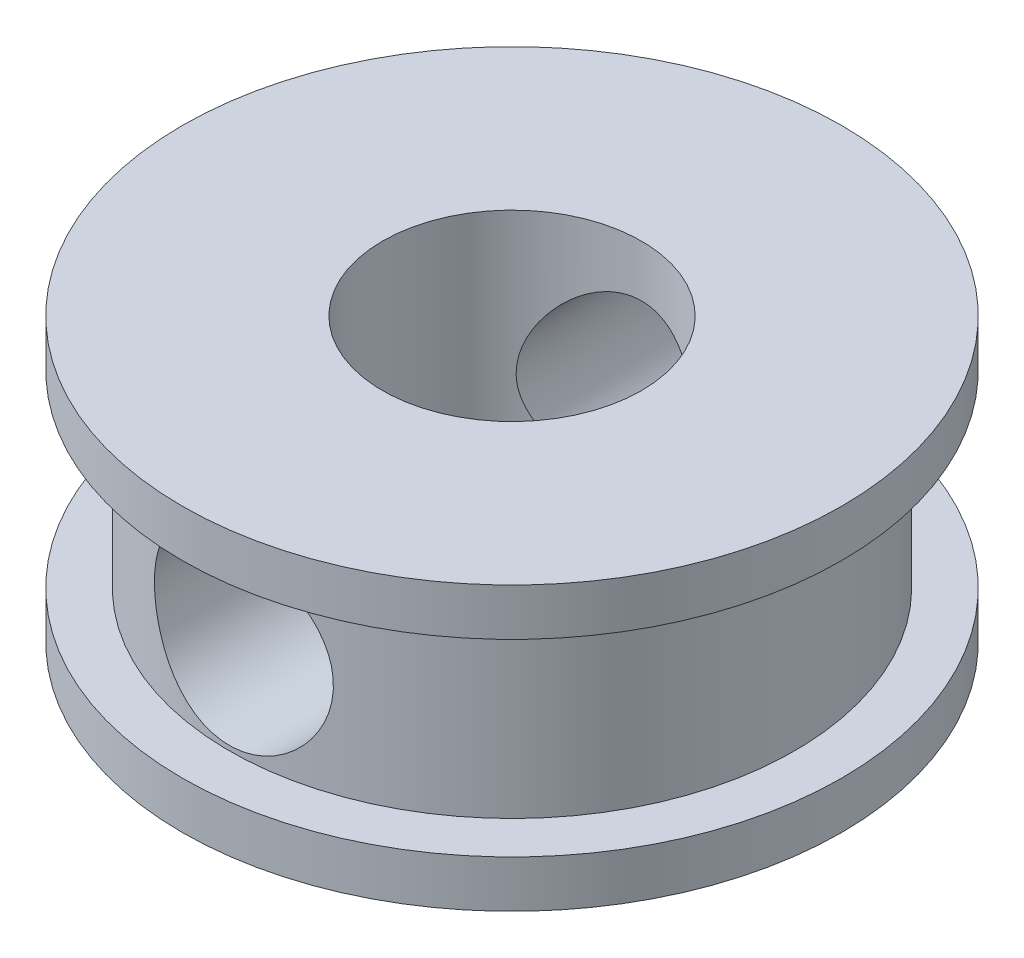
from build123d import *

# Parameters (mm, degrees)
SKETCH_4_R               = 1.9
CUT_EXTRUDE_3_DEPTH      = 8
CUT_EXTRUDE_3_DEPTH_BACK = 8
SKETCH_5_R               = 2.75
CUT_EXTRUDE_4_DEPTH      = 10


with BuildPart() as part:
    # 스케치2 → 회전2 (revolve)
    with BuildSketch(Plane.XY):
        Polygon((0, 3.263948498), (7, 3.263948498), (7, 2.263948498), (6, 2.263948498), (6, -1.736051502), (7, -1.736051502), (7, -2.736051502), (0, -2.736051502), align=None)
    revolve(axis=Axis((0, 3.263948498, 0), (0, -1, 0)))

    # 스케치4 → 컷-돌출3 (cut, two sides)
    with BuildSketch(Plane.XY) as cut_extrude_3_sk:
        with Locations((0, 0.263948498)):
            Circle(SKETCH_4_R)
    extrude(amount=CUT_EXTRUDE_3_DEPTH, mode=Mode.SUBTRACT)
    extrude(cut_extrude_3_sk.sketch, amount=-CUT_EXTRUDE_3_DEPTH_BACK, mode=Mode.SUBTRACT)

    # 스케치5 → 컷-돌출4 (cut)
    with BuildSketch(Plane(origin=(0, 3.263948498, 0), x_dir=(1, 0, 0), z_dir=(0, 1, 0))):
        Circle(SKETCH_5_R)
    extrude(amount=-CUT_EXTRUDE_4_DEPTH, mode=Mode.SUBTRACT)


solid = part.part
